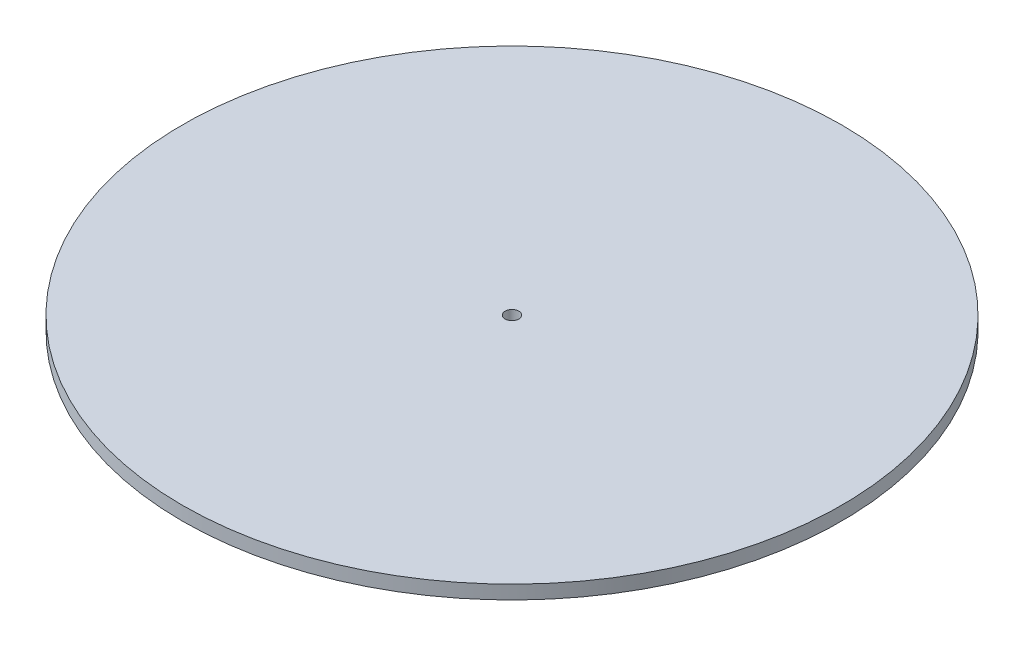
from build123d import *

# Parameters (mm, degrees)
SKETCH1_R           = 152.4
SKETCH1_R_2         = 3.175
BOSS_EXTRUDE1_DEPTH = 6.35


with BuildPart() as part:
    # Sketch1 → Boss-Extrude1 (new body)
    with BuildSketch(Plane(origin=(0, 0, 0), x_dir=(1, 0, 0), z_dir=(0, 1, 0))):
        Circle(SKETCH1_R)
        Circle(SKETCH1_R_2, mode=Mode.SUBTRACT)
    extrude(amount=BOSS_EXTRUDE1_DEPTH)


solid = part.part
